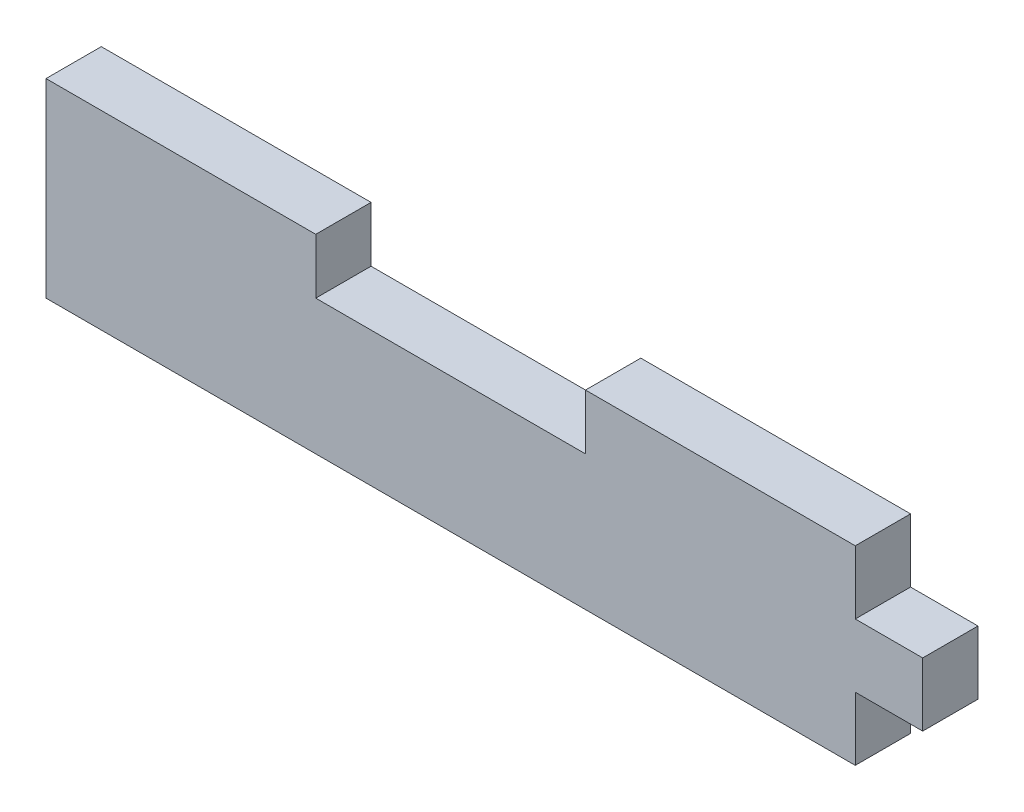
from build123d import *

# Parameters (mm, degrees)
BOSS_EXTRUDE1_DEPTH = 5.207


with BuildPart() as part:
    # Sketch1 → Boss-Extrude1 (new body)
    with BuildSketch(Plane.XY):
        Polygon((50.8, 17.907), (76.2, 17.907), (76.2, 11.938), (82.55, 11.938), (82.55, 5.969), (76.2, 5.969), (76.2, 0), (0, 0), (0, 17.907), (25.4, 17.907), (25.4, 12.7), (50.8, 12.7), align=None)
    extrude(amount=BOSS_EXTRUDE1_DEPTH)


solid = part.part
